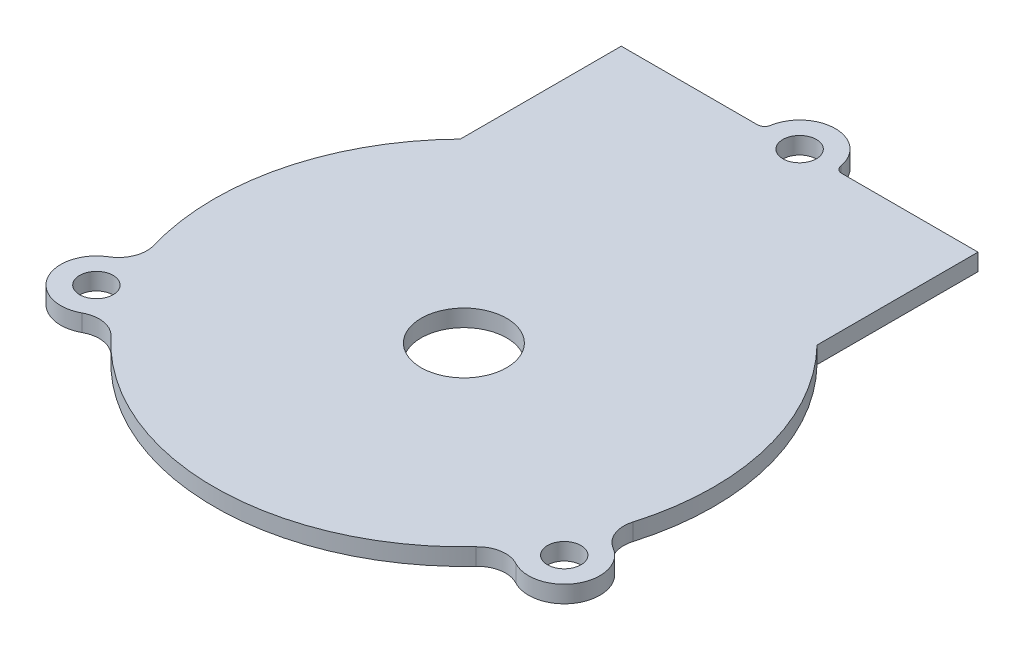
from build123d import *

# Parameters (mm, degrees)
SKETCH1_R                  = 35
SKETCH1_R_2                = 6
SKETCH1_R_3                = 5
SKETCH1_W                  = 50
SKETCH1_H                  = 25
BOSS_EXTRUDE1_DEPTH        = 2.38125
FILLET1_R                  = 4
FILLET2_R                  = 4
FILLET3_R                  = 1
F_4_7_4_7_DIAMETER_HOLE1_D = 4.7


with BuildPart() as part:
    # Sketch1 → Boss-Extrude1 (new body)
    with BuildSketch(Plane(origin=(0, 0, 0), x_dir=(1, 0, 0), z_dir=(0, 1, 0))):
        with Locations((32.785, 18.724314586)):
            Circle(SKETCH1_R)
        with Locations((32.785, 18.724314586)):
            Circle(SKETCH1_R_2, mode=Mode.SUBTRACT)
        with Locations((65.57, 0)):
            Circle(SKETCH1_R_3)
        Circle(SKETCH1_R_3)
        with Locations((32.785, 65.782929207)):
            Circle(SKETCH1_R_3)
        with Locations((32.785, 53.282929207)):
            Rectangle(SKETCH1_W, SKETCH1_H)
    extrude(amount=BOSS_EXTRUDE1_DEPTH)

    # Fillet1
    fillet1_edges = [part.edges().sort_by_distance(p)[0] for p in [
        (64.966328407, 1.190625, -4.963424282),
        (60.988257258, 1.190625, 2.001907453),
    ]]
    fillet(fillet1_edges, radius=FILLET1_R)

    # Fillet2
    fillet2_edges = [part.edges().sort_by_distance(p)[0] for p in [
        (0.603671593, 1.190625, -4.963424282),
        (4.581742742, 1.190625, 2.001907453),
    ]]
    fillet(fillet2_edges, radius=FILLET2_R)

    # Fillet3
    fillet3_edges = [part.edges().sort_by_distance(p)[0] for p in [
        (37.785, 1.190625, -65.782929207),
        (27.785, 1.190625, -65.782929207),
    ]]
    fillet(fillet3_edges, radius=FILLET3_R)

    # Ø4.7 (4.7) Diameter Hole1 (through all)
    with Locations(Plane(origin=(0, 2.38125, 0), x_dir=(1, 0, 0), z_dir=(0, 1, 0))):
        with Locations((32.785, 65.782929207), (0, 0), (65.57, 0)):
            Hole(F_4_7_4_7_DIAMETER_HOLE1_D / 2)


solid = part.part
